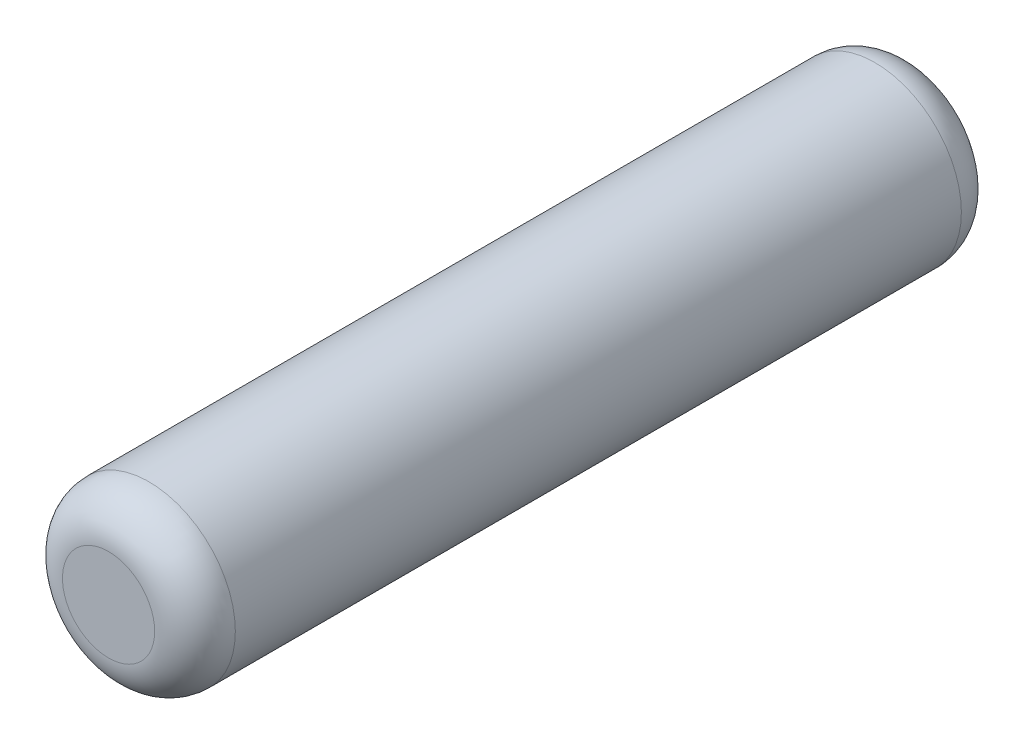
from build123d import *

# Parameters (mm, degrees)
SKETCH1_R           = 0.75
BOSS_EXTRUDE1_DEPTH = 3.5
FILLET1_R           = 0.35


with BuildPart() as part:
    # Sketch1 → Boss-Extrude1 (new body, symmetric)
    with BuildSketch(Plane.XY):
        Circle(SKETCH1_R)
    extrude(amount=BOSS_EXTRUDE1_DEPTH, both=True)

    # Fillet1
    fillet1_edges = [part.edges().sort_by_distance(p)[0] for p in [
        (-0.75, 0, -3.5),
        (-0.75, 0, 3.5),
    ]]
    fillet(fillet1_edges, radius=FILLET1_R)


solid = part.part
